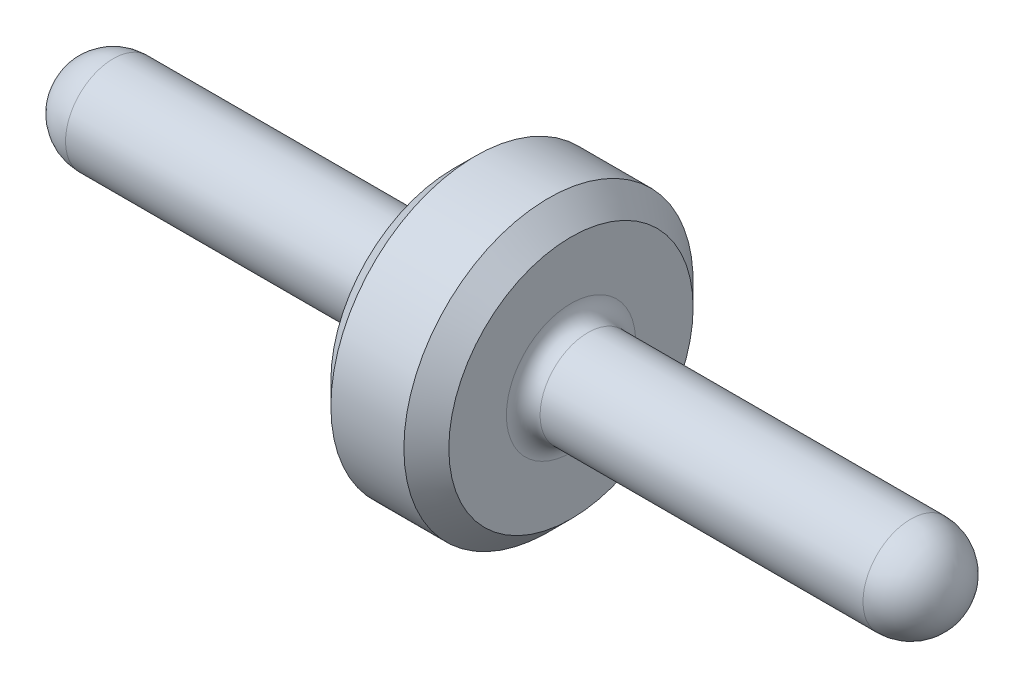
from build123d import *


with BuildPart() as part:
    # Sketch1 → RevolutionAngle1 (revolve)
    with BuildSketch(Plane.XY):
        with BuildLine():
            Line((0.2159, 0.2159), (1.6764, 0.2159))
            ThreePointArc((1.6764, 0.2159), (1.730281537, 0.238218463), (1.7526, 0.2921))
            Line((1.7526, 0.2921), (1.7526, 0.55245))
            Line((1.7526, 0.55245), (1.8542, 0.65405))
            Line((1.8542, 0.65405), (2.1844, 0.65405))
            Line((2.1844, 0.65405), (2.286, 0.55245))
            Line((2.286, 0.55245), (2.286, 0.2921))
            ThreePointArc((2.286, 0.2921), (2.308318463, 0.238218463), (2.3622, 0.2159))
            Line((2.3622, 0.2159), (3.8227, 0.2159))
            ThreePointArc((3.8227, 0.2159), (3.975364354, 0.152664354), (4.0386, 0))
            Line((4.0386, 0), (0, 0))
            ThreePointArc((0, 0), (0.063235646, 0.152664354), (0.2159, 0.2159))
        make_face()
    revolve(axis=Axis((0, 0, 0), (1, 0, 0)))


solid = part.part
